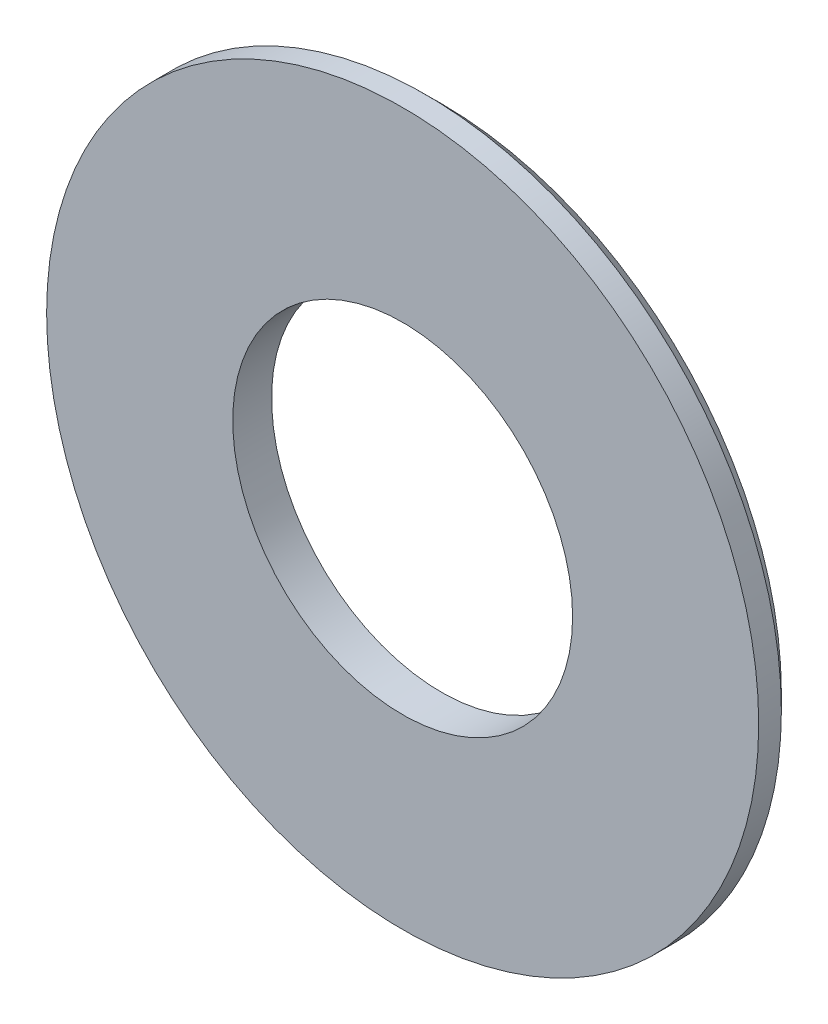
from build123d import *

# Parameters (mm, degrees)
CROQUIS1_W    = 5.75
CROQUIS1_H    = 1.2
CHAFL_N1_SIZE = 0.5


with BuildPart() as part:
    # Croquis1 → Revolución1 (revolve)
    with BuildSketch(Plane(origin=(0, 0, 0), x_dir=(1, 0, 0), z_dir=(0, 1, 0))):
        with Locations((8.125, -0.6)):
            Rectangle(CROQUIS1_W, CROQUIS1_H)
    revolve(axis=Axis((0, 0, 0), (0, 0, 1)))

    # Chaflán1
    chafl_n1_edges = [part.edges().sort_by_distance(p)[0] for p in [
        (-11, 0, 0),
    ]]
    chamfer(chafl_n1_edges, length=CHAFL_N1_SIZE)


solid = part.part
